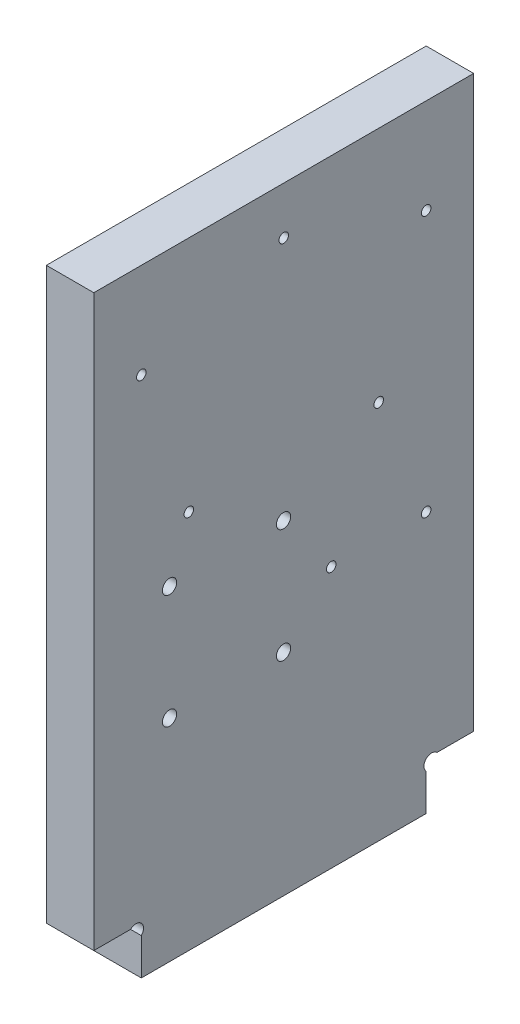
from build123d import *

# Parameters (mm, degrees)
EXTRUSION1_DEPTH        = 10
ESQUISSE2_R             = 1
ESQUISSE2_R_2           = 1.5
ENL_V_MAT_EXTRU_1_DEPTH = 11


with BuildPart() as part:
    # Esquisse1 → Extrusion1 (new body)
    with BuildSketch(Plane(origin=(0, 0, 0), x_dir=(0, 0, -1), z_dir=(1, 0, 0))):
        with BuildLine():
            Line((10, 7.7372583), (10, 0))
            Line((10, 0), (70, 0))
            Line((70, 0), (70, 7.7372583))
            ThreePointArc((70, 7.7372583), (70, 10), (72.2627417, 10))
            Line((72.2627417, 10), (80, 10))
            Line((80, 10), (80, 130))
            Line((80, 130), (0, 130))
            Line((0, 130), (0, 10))
            Line((0, 10), (7.7372583, 10))
            ThreePointArc((7.7372583, 10), (10, 10), (10, 7.7372583))
        make_face()
    extrude(amount=EXTRUSION1_DEPTH)

    # Esquisse2 → Enlèv. mat.-Extru.1 (cut, through all)
    with BuildSketch(Plane(origin=(10, 0, 0), x_dir=(0, 0, -1), z_dir=(1, 0, 0))):
        with Locations((60, 80)):
            Circle(ESQUISSE2_R)
        with Locations((10, 110)):
            Circle(ESQUISSE2_R)
        with Locations(Location((20, 80, 0), (0, 0, 180))):  # turned: the seam where the file's is
            Circle(ESQUISSE2_R)
        with Locations((70, 110)):
            Circle(ESQUISSE2_R)
        with Locations((15.95, 68.45)):
            Circle(ESQUISSE2_R_2)
        with Locations((15.95, 44.45)):
            Circle(ESQUISSE2_R_2)
        with Locations((39.95, 44.45)):
            Circle(ESQUISSE2_R_2)
        with Locations((39.95, 68.45)):
            Circle(ESQUISSE2_R_2)
        with Locations((40, 120)):
            Circle(ESQUISSE2_R)
        with Locations((70, 55)):
            Circle(ESQUISSE2_R)
        with Locations((50, 55)):
            Circle(ESQUISSE2_R)
    extrude(amount=-ENL_V_MAT_EXTRU_1_DEPTH, mode=Mode.SUBTRACT)


solid = part.part
